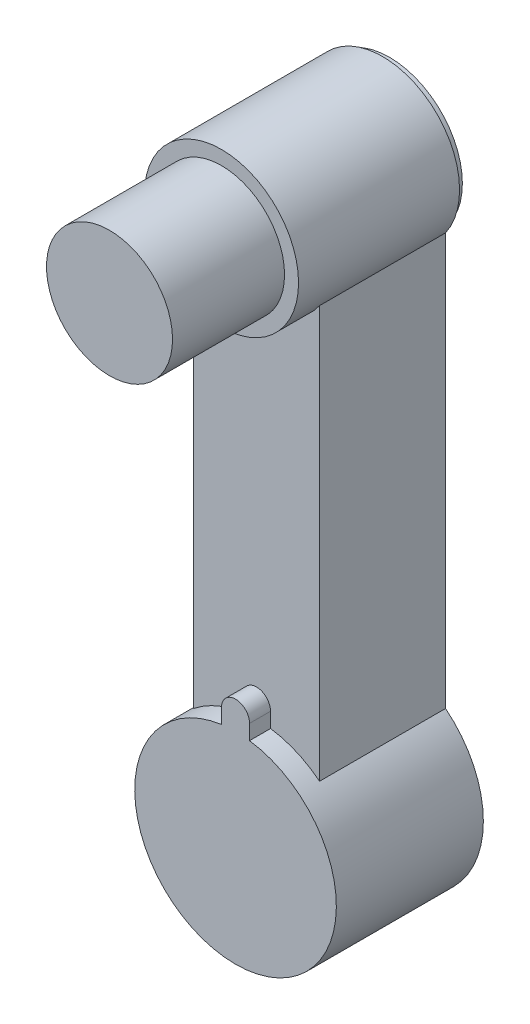
from build123d import *

# Parameters (mm, degrees)
BOSS_EXTRUDE5_DEPTH  = 90
BOSS_EXTRUDE6_DEPTH  = 115
BOSS_EXTRUDE7_DEPTH  = 105
BOSS_EXTRUDE8_DEPTH  = 15
SKETCH17_R           = 45
BOSS_EXTRUDE9_DEPTH  = 80
SKETCH18_R           = 52
BOSS_EXTRUDE10_DEPTH = 5


with BuildPart() as part:
    # Sketch11 → Boss-Extrude5 (new body)
    with BuildSketch(Plane.XY):
        with BuildLine():
            ThreePointArc((-45, 56.204981986), (0, 72), (45, 56.204981986))
            Line((45, 56.204981986), (45, 350.377223398))
            ThreePointArc((45, 350.377223398), (0, 327), (-45, 350.377223398))
            Line((-45, 350.377223398), (-45, 56.204981986))
        make_face()
    extrude(amount=BOSS_EXTRUDE5_DEPTH)

    # Sketch11_3 → Boss-Extrude6 (add)
    with BuildSketch(Plane.XY):
        with BuildLine():
            ThreePointArc((-45, 350.377223398), (0, 327), (45, 350.377223398))
            ThreePointArc((45, 350.377223398), (52.440442409, 365.416876048), (55, 382))
            ThreePointArc((55, 382), (-16.583123952, 434.440442409), (-45, 350.377223398))
        make_face()
    extrude(amount=BOSS_EXTRUDE6_DEPTH)

    # Sketch11_4 → Boss-Extrude7 (add)
    with BuildSketch(Plane.XY):
        with BuildLine():
            ThreePointArc((72, 0), (64.899922958, 31.176914536), (45, 56.204981986))
            ThreePointArc((45, 56.204981986), (0, 72), (-45, 56.204981986))
            ThreePointArc((-45, 56.204981986), (-31.176914536, -64.899922958), (72, 0))
        make_face()
    extrude(amount=BOSS_EXTRUDE7_DEPTH)

    # Sketch13 → Boss-Extrude8 (add)
    with BuildSketch(Plane.XY.offset(90)):
        with BuildLine():
            Line((10, 82), (10, 71.30217388))
            Line((10, 71.30217388), (-10, 71.30217388))
            Line((-10, 71.30217388), (-10, 82))
            ThreePointArc((-10, 82), (0, 92), (10, 82))
        make_face()
    extrude(amount=BOSS_EXTRUDE8_DEPTH)

    # Sketch17 → Boss-Extrude9 (add)
    with BuildSketch(Plane.XY.offset(115)):
        with Locations((0, 382)):
            Circle(SKETCH17_R)
    extrude(amount=BOSS_EXTRUDE9_DEPTH)

    # Sketch18 → Boss-Extrude10 (add)
    with BuildSketch(Plane(origin=(0, 0, 0), x_dir=(-1, 0, 0), z_dir=(0, 0, -1))):
        with Locations((0, 382)):
            Circle(SKETCH18_R)
    extrude(amount=BOSS_EXTRUDE10_DEPTH)


solid = part.part
